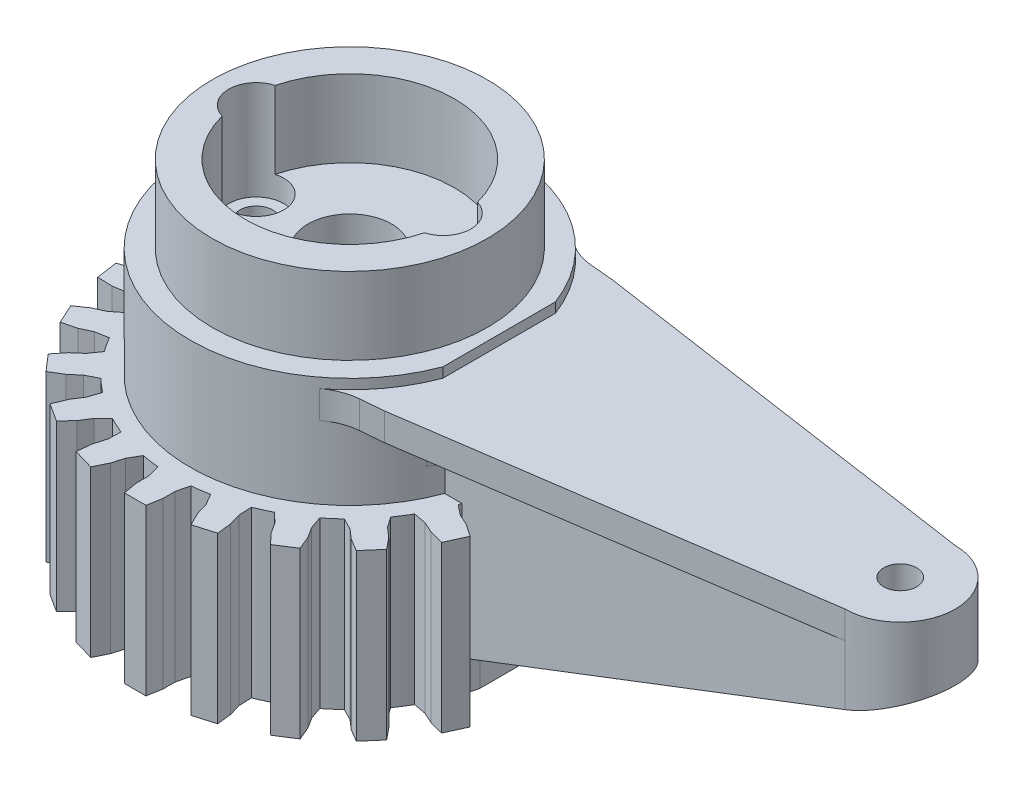
from build123d import *

# Parameters (mm, degrees)
SKETCH1_R            = 14.5
BOSS_EXTRUDE1_DEPTH  = 2
SKETCH2_R            = 3.8
SKETCH2_R_2          = 1.5
CUT_EXTRUDE1_DEPTH   = 2.5
BOSS_EXTRUDE2_START  = 7
SKETCH3_R            = 14.5
SKETCH3_R_2          = 12.5
BOSS_EXTRUDE2_DEPTH  = 7
BOSS_EXTRUDE3_START  = 1
SKETCH4_R            = 14.5
SKETCH4_R_2          = 3.8
SKETCH4_R_3          = 1.5
BOSS_EXTRUDE3_DEPTH  = 1
SKETCH5_R            = 2.6
SKETCH5_R_2          = 2.5
CUT_EXTRUDE2_DEPTH   = 2
BOSS_EXTRUDE4_START  = -3.5
SKETCH6_R            = 1.5
BOSS_EXTRUDE4_DEPTH  = 3.5
BOSS_EXTRUDE5_START  = 30
SKETCH9_R            = 12.5
BOSS_EXTRUDE5_DEPTH  = 30
SKETCH15_R           = 12.5
SKETCH15_R_2         = 9.5
BOSS_EXTRUDE9_DEPTH  = 7
SKETCH17_R           = 2.5
CUT_EXTRUDE5_DEPTH   = 7
SKETCH18_W           = 71.644805376
SKETCH18_H           = 13.532805393
CUT_EXTRUDE6_DEPTH   = 0.9
SKETCH19_W           = 61.579455678
SKETCH19_H           = 54.934190677
CUT_EXTRUDE7_DEPTH   = 15
BOSS_EXTRUDE14_START = -2.5
BOSS_EXTRUDE14_DEPTH = 2.5
FILLET2_R            = 5
SKETCH21_W           = 41.145247831
SKETCH21_H           = 10
BOSS_EXTRUDE15_DEPTH = 4
CUT_EXTRUDE8_DEPTH   = 17
FILLET5_R            = 2
CUT_EXTRUDE9_START   = -8
SKETCH23_R           = 1.5
CUT_EXTRUDE9_DEPTH   = 8
SKETCH24_R           = 1.5
CUT_EXTRUDE10_DEPTH  = 8
SKETCH27_W           = 31.221224177
SKETCH27_H           = 10
BOSS_EXTRUDE16_DEPTH = 19
CUT_EXTRUDE11_DEPTH  = 10
CUT_EXTRUDE12_DEPTH  = 3
SKETCH33_R           = 5
SKETCH33_R_2         = 1.5
BOSS_EXTRUDE19_DEPTH = 6
BOSS_EXTRUDE20_DEPTH = 5
BOSS_EXTRUDE21_DEPTH = 10
CUT_EXTRUDE13_START  = -10
SKETCH36_R           = 1.5
CUT_EXTRUDE13_DEPTH  = 10


with BuildPart() as part:
    # Sketch1 → Boss-Extrude1 (new body)
    with BuildSketch(Plane(origin=(0, 0, 0), x_dir=(1, 0, 0), z_dir=(0, 1, 0))):
        Circle(SKETCH1_R)
    extrude(amount=BOSS_EXTRUDE1_DEPTH)

    # Sketch2 → Cut-Extrude1 (cut)
    with BuildSketch(Plane(origin=(0, 2, 0), x_dir=(1, 0, 0), z_dir=(0, 1, 0))):
        Circle(SKETCH2_R)
        with Locations((-8.5, 0)):
            Circle(SKETCH2_R_2)
        with Locations((8.5, 0)):
            Circle(SKETCH2_R_2)
    extrude(amount=-CUT_EXTRUDE1_DEPTH, mode=Mode.SUBTRACT)

    # Sketch3 → Boss-Extrude2 (add)
    with BuildSketch(Plane.XZ.offset(BOSS_EXTRUDE2_START)):
        Circle(SKETCH3_R)
        Circle(SKETCH3_R_2, mode=Mode.SUBTRACT)
    extrude(amount=-BOSS_EXTRUDE2_DEPTH)

    # Sketch4 → Boss-Extrude3 (add)
    with BuildSketch(Plane(origin=(0, 2, 0), x_dir=(1, 0, 0), z_dir=(0, 1, 0)).offset(BOSS_EXTRUDE3_START)):
        Circle(SKETCH4_R)
        Circle(SKETCH4_R_2, mode=Mode.SUBTRACT)
        with Locations((8.5, 0)):
            Circle(SKETCH4_R_3, mode=Mode.SUBTRACT)
        with Locations((-8.5, 0)):
            Circle(SKETCH4_R_3, mode=Mode.SUBTRACT)
    extrude(amount=-BOSS_EXTRUDE3_DEPTH)

    # Sketch5 → Cut-Extrude2 (cut)
    with BuildSketch(Plane(origin=(0, 3, 0), x_dir=(1, 0, 0), z_dir=(0, 1, 0))):
        with Locations((8.5, 0)):
            Circle(SKETCH5_R)
        with Locations((-8.5, 0)):
            Circle(SKETCH5_R_2)
    extrude(amount=-CUT_EXTRUDE2_DEPTH, mode=Mode.SUBTRACT)

    # Sketch6 → Boss-Extrude4 (add)
    with BuildSketch(Plane(origin=(0, 3, 0), x_dir=(1, 0, 0), z_dir=(0, 1, 0)).offset(BOSS_EXTRUDE4_START)):
        with BuildLine():
            Line((70, 5), (60, 5))
            Line((60, 5), (13.610657589, 5))
            ThreePointArc((13.610657589, 5), (14.275933158, 2.539238563), (14.5, 0))
            ThreePointArc((14.5, 0), (14.275933158, -2.539238563), (13.610657589, -5))
            Line((13.610657589, -5), (60, -5))
            Line((60, -5), (70, -5))
            Line((70, -5), (73, -5))
            ThreePointArc((73, -5), (78, 0), (73, 5))
            Line((73, 5), (70, 5))
        make_face()
        with Locations((73, 0)):
            Circle(SKETCH6_R, mode=Mode.SUBTRACT)
    extrude(amount=BOSS_EXTRUDE4_DEPTH)

    # Sketch9 → Boss-Extrude5 (add)
    with BuildSketch(Plane(origin=(0, -7, 0), x_dir=(-1, 0, 0), z_dir=(0, -1, 0)).offset(BOSS_EXTRUDE5_START)):
        with BuildLine():
            Line((0.977254255, 19.494569665), (-0.977254255, 19.494569665))
            Line((-0.977254255, 19.494569665), (-1.208206331, 18.184775353))
            Line((-1.208206331, 18.184775353), (-1.208206331, 17.065775353))
            Line((-1.208206331, 17.065775353), (-1.493190324, 15.922766988))
            ThreePointArc((-1.493190324, 15.922766988), (-2.275988159, 15.82984535), (-3.053256231, 15.698463373))
            Line((-3.053256231, 15.698463373), (-3.648719039, 16.7148826))
            Line((-3.648719039, 16.7148826), (-3.96397777, 17.788555237))
            Line((-3.96397777, 17.788555237), (-4.554586365, 18.980226957))
            Line((-4.554586365, 18.980226957), (-6.429923547, 18.429578277))
            Line((-6.429923547, 18.429578277), (-6.282508741, 17.107773119))
            Line((-6.282508741, 17.107773119), (-5.96725001, 16.034100482))
            Line((-5.96725001, 16.034100482), (-5.91866748, 14.857102717))
            ThreePointArc((-5.91866748, 14.857102717), (-6.643577451, 14.547405423), (-7.352346125, 14.202363618))
            Line((-7.352346125, 14.202363618), (-8.210046893, 15.009849465))
            Line((-8.210046893, 15.009849465), (-8.815023968, 15.951212168))
            Line((-8.815023968, 15.951212168), (-9.717441485, 16.928219141))
            Line((-9.717441485, 16.928219141), (-11.361678674, 15.871532062))
            Line((-11.361678674, 15.871532062), (-10.847839657, 14.644800851))
            Line((-10.847839657, 14.644800851), (-10.242862582, 13.703438148))
            Line((-10.242862582, 13.703438148), (-9.864649396, 12.587804343))
            ThreePointArc((-9.864649396, 12.587804343), (-10.472943609, 12.086421226), (-11.055792662, 11.555672828))
            Line((-11.055792662, 11.555672828), (-12.106245574, 12.088807594))
            Line((-12.106245574, 12.088807594), (-12.951929348, 12.821596755))
            Line((-12.951929348, 12.821596755), (-14.093047288, 13.504787686))
            Line((-14.093047288, 13.504787686), (-15.372978165, 12.027668711))
            Line((-15.372978165, 12.027668711), (-14.534343118, 10.995393914))
            Line((-14.534343118, 10.995393914), (-13.688659344, 10.262604753))
            Line((-13.688659344, 10.262604753), (-13.011456085, 9.298716924))
            ThreePointArc((-13.011456085, 9.298716924), (-13.453854161, 8.646267062), (-13.863564629, 7.972810149))
            Line((-13.863564629, 7.972810149), (-15.021668238, 8.188402426))
            Line((-15.021668238, 8.188402426), (-16.039546441, 8.653251826))
            Line((-16.039546441, 8.653251826), (-17.326918214, 8.987278649))
            Line((-17.326918214, 8.987278649), (-18.138850392, 7.209395173))
            Line((-18.138850392, 7.209395173), (-17.043360539, 6.455205554))
            Line((-17.043360539, 6.455205554), (-16.025482336, 5.990356154))
            Line((-16.025482336, 5.990356154), (-15.104151985, 5.256302761))
            ThreePointArc((-15.104151985, 5.256302761), (-15.344813462, 4.505643762), (-15.548193039, 3.744037809))
            Line((-15.548193039, 3.744037809), (-16.720124678, 3.624621592))
            Line((-16.720124678, 3.624621592), (-17.827734872, 3.783871896))
            Line((-17.827734872, 3.783871896), (-19.157065273, 3.741673745))
            Line((-19.157065273, 3.741673745), (-19.435220836, 1.807059313))
            Line((-19.435220836, 1.807059313), (-18.171626249, 1.39205483))
            Line((-18.171626249, 1.39205483), (-17.064016056, 1.232804526))
            Line((-17.064016056, 1.232804526), (-15.973199318, 0.788054209))
            ThreePointArc((-15.973199318, 0.788054209), (-15.992627235, 0), (-15.973199318, -0.788054209))
            Line((-15.973199318, -0.788054209), (-17.064016056, -1.232804526))
            Line((-17.064016056, -1.232804526), (-18.171626249, -1.39205483))
            Line((-18.171626249, -1.39205483), (-19.435220836, -1.807059313))
            Line((-19.435220836, -1.807059313), (-19.157065273, -3.741673745))
            Line((-19.157065273, -3.741673745), (-17.827734872, -3.783871896))
            Line((-17.827734872, -3.783871896), (-16.720124678, -3.624621592))
            Line((-16.720124678, -3.624621592), (-15.548193039, -3.744037809))
            ThreePointArc((-15.548193039, -3.744037809), (-15.344813462, -4.505643762), (-15.104151985, -5.256302761))
            Line((-15.104151985, -5.256302761), (-16.025482336, -5.990356154))
            Line((-16.025482336, -5.990356154), (-17.043360539, -6.455205554))
            Line((-17.043360539, -6.455205554), (-18.138850392, -7.209395173))
            Line((-18.138850392, -7.209395173), (-17.326918214, -8.987278649))
            Line((-17.326918214, -8.987278649), (-16.039546441, -8.653251826))
            Line((-16.039546441, -8.653251826), (-15.021668238, -8.188402426))
            Line((-15.021668238, -8.188402426), (-13.863564629, -7.972810149))
            ThreePointArc((-13.863564629, -7.972810149), (-13.453854161, -8.646267062), (-13.011456085, -9.298716924))
            Line((-13.011456085, -9.298716924), (-13.688659344, -10.262604753))
            Line((-13.688659344, -10.262604753), (-14.534343118, -10.995393914))
            Line((-14.534343118, -10.995393914), (-15.372978165, -12.027668711))
            Line((-15.372978165, -12.027668711), (-14.093047288, -13.504787686))
            Line((-14.093047288, -13.504787686), (-12.951929348, -12.821596755))
            Line((-12.951929348, -12.821596755), (-12.106245574, -12.088807594))
            Line((-12.106245574, -12.088807594), (-11.055792662, -11.555672828))
            ThreePointArc((-11.055792662, -11.555672828), (-10.472943609, -12.086421226), (-9.864649396, -12.587804343))
            Line((-9.864649396, -12.587804343), (-10.242862582, -13.703438148))
            Line((-10.242862582, -13.703438148), (-10.847839657, -14.644800851))
            Line((-10.847839657, -14.644800851), (-11.361678674, -15.871532062))
            Line((-11.361678674, -15.871532062), (-9.717441485, -16.928219141))
            Line((-9.717441485, -16.928219141), (-8.815023968, -15.951212168))
            Line((-8.815023968, -15.951212168), (-8.210046893, -15.009849465))
            Line((-8.210046893, -15.009849465), (-7.352346125, -14.202363618))
            ThreePointArc((-7.352346125, -14.202363618), (-6.643577451, -14.547405423), (-5.91866748, -14.857102717))
            Line((-5.91866748, -14.857102717), (-5.96725001, -16.034100482))
            Line((-5.96725001, -16.034100482), (-6.282508741, -17.107773119))
            Line((-6.282508741, -17.107773119), (-6.429923547, -18.429578277))
            Line((-6.429923547, -18.429578277), (-4.554586365, -18.980226957))
            Line((-4.554586365, -18.980226957), (-3.96397777, -17.788555237))
            Line((-3.96397777, -17.788555237), (-3.648719039, -16.7148826))
            Line((-3.648719039, -16.7148826), (-3.053256231, -15.698463373))
            ThreePointArc((-3.053256231, -15.698463373), (-2.275988159, -15.82984535), (-1.493190324, -15.922766988))
            Line((-1.493190324, -15.922766988), (-1.208206331, -17.065775353))
            Line((-1.208206331, -17.065775353), (-1.208206331, -18.184775353))
            Line((-1.208206331, -18.184775353), (-0.977254255, -19.494569665))
            Line((-0.977254255, -19.494569665), (0.977254255, -19.494569665))
            Line((0.977254255, -19.494569665), (1.208206331, -18.184775353))
            Line((1.208206331, -18.184775353), (1.208206331, -17.065775353))
            Line((1.208206331, -17.065775353), (1.493190324, -15.922766988))
            ThreePointArc((1.493190324, -15.922766988), (2.275988159, -15.82984535), (3.053256231, -15.698463373))
            Line((3.053256231, -15.698463373), (3.648719039, -16.7148826))
            Line((3.648719039, -16.7148826), (3.96397777, -17.788555237))
            Line((3.96397777, -17.788555237), (4.554586365, -18.980226957))
            Line((4.554586365, -18.980226957), (6.429923547, -18.429578277))
            Line((6.429923547, -18.429578277), (6.282508741, -17.107773119))
            Line((6.282508741, -17.107773119), (5.96725001, -16.034100482))
            Line((5.96725001, -16.034100482), (5.91866748, -14.857102717))
            ThreePointArc((5.91866748, -14.857102717), (6.643577451, -14.547405423), (7.352346125, -14.202363618))
            Line((7.352346125, -14.202363618), (8.210046893, -15.009849465))
            Line((8.210046893, -15.009849465), (8.815023968, -15.951212168))
            Line((8.815023968, -15.951212168), (9.717441485, -16.928219141))
            Line((9.717441485, -16.928219141), (11.361678674, -15.871532062))
            Line((11.361678674, -15.871532062), (10.847839657, -14.644800851))
            Line((10.847839657, -14.644800851), (10.242862582, -13.703438148))
            Line((10.242862582, -13.703438148), (9.864649396, -12.587804343))
            ThreePointArc((9.864649396, -12.587804343), (10.472943609, -12.086421226), (11.055792662, -11.555672828))
            Line((11.055792662, -11.555672828), (12.106245574, -12.088807594))
            Line((12.106245574, -12.088807594), (12.951929348, -12.821596755))
            Line((12.951929348, -12.821596755), (14.093047288, -13.504787686))
            Line((14.093047288, -13.504787686), (15.372978165, -12.027668711))
            Line((15.372978165, -12.027668711), (14.534343118, -10.995393914))
            Line((14.534343118, -10.995393914), (13.688659344, -10.262604753))
            Line((13.688659344, -10.262604753), (13.011456085, -9.298716924))
            ThreePointArc((13.011456085, -9.298716924), (13.453854161, -8.646267062), (13.863564629, -7.972810149))
            Line((13.863564629, -7.972810149), (15.021668238, -8.188402426))
            Line((15.021668238, -8.188402426), (16.039546441, -8.653251826))
            Line((16.039546441, -8.653251826), (17.326918214, -8.987278649))
            Line((17.326918214, -8.987278649), (18.138850392, -7.209395173))
            Line((18.138850392, -7.209395173), (17.043360539, -6.455205554))
            Line((17.043360539, -6.455205554), (16.025482336, -5.990356154))
            Line((16.025482336, -5.990356154), (15.104151985, -5.256302761))
            ThreePointArc((15.104151985, -5.256302761), (15.344813462, -4.505643762), (15.548193039, -3.744037809))
            Line((15.548193039, -3.744037809), (16.720124678, -3.624621592))
            Line((16.720124678, -3.624621592), (17.827734872, -3.783871896))
            Line((17.827734872, -3.783871896), (19.157065273, -3.741673745))
            Line((19.157065273, -3.741673745), (19.435220836, -1.807059313))
            Line((19.435220836, -1.807059313), (18.171626249, -1.39205483))
            Line((18.171626249, -1.39205483), (17.064016056, -1.232804526))
            Line((17.064016056, -1.232804526), (15.973199318, -0.788054209))
            ThreePointArc((15.973199318, -0.788054209), (15.992627235, 0), (15.973199318, 0.788054209))
            Line((15.973199318, 0.788054209), (17.064016056, 1.232804526))
            Line((17.064016056, 1.232804526), (18.171626249, 1.39205483))
            Line((18.171626249, 1.39205483), (19.435220836, 1.807059313))
            Line((19.435220836, 1.807059313), (19.157065273, 3.741673745))
            Line((19.157065273, 3.741673745), (17.827734872, 3.783871896))
            Line((17.827734872, 3.783871896), (16.720124678, 3.624621592))
            Line((16.720124678, 3.624621592), (15.548193039, 3.744037809))
            ThreePointArc((15.548193039, 3.744037809), (15.344813462, 4.505643762), (15.104151985, 5.256302761))
            Line((15.104151985, 5.256302761), (16.025482336, 5.990356154))
            Line((16.025482336, 5.990356154), (17.043360539, 6.455205554))
            Line((17.043360539, 6.455205554), (18.138850392, 7.209395173))
            Line((18.138850392, 7.209395173), (17.326918214, 8.987278649))
            Line((17.326918214, 8.987278649), (16.039546441, 8.653251826))
            Line((16.039546441, 8.653251826), (15.021668238, 8.188402426))
            Line((15.021668238, 8.188402426), (13.863564629, 7.972810149))
            ThreePointArc((13.863564629, 7.972810149), (13.453854161, 8.646267062), (13.011456085, 9.298716924))
            Line((13.011456085, 9.298716924), (13.688659344, 10.262604753))
            Line((13.688659344, 10.262604753), (14.534343118, 10.995393914))
            Line((14.534343118, 10.995393914), (15.372978165, 12.027668711))
            Line((15.372978165, 12.027668711), (14.093047288, 13.504787686))
            Line((14.093047288, 13.504787686), (12.951929348, 12.821596755))
            Line((12.951929348, 12.821596755), (12.106245574, 12.088807594))
            Line((12.106245574, 12.088807594), (11.055792662, 11.555672828))
            ThreePointArc((11.055792662, 11.555672828), (10.472943609, 12.086421226), (9.864649396, 12.587804343))
            Line((9.864649396, 12.587804343), (10.242862582, 13.703438148))
            Line((10.242862582, 13.703438148), (10.847839657, 14.644800851))
            Line((10.847839657, 14.644800851), (11.361678674, 15.871532062))
            Line((11.361678674, 15.871532062), (9.717441485, 16.928219141))
            Line((9.717441485, 16.928219141), (8.815023968, 15.951212168))
            Line((8.815023968, 15.951212168), (8.210046893, 15.009849465))
            Line((8.210046893, 15.009849465), (7.352346125, 14.202363618))
            ThreePointArc((7.352346125, 14.202363618), (6.643577451, 14.547405423), (5.91866748, 14.857102717))
            Line((5.91866748, 14.857102717), (5.96725001, 16.034100482))
            Line((5.96725001, 16.034100482), (6.282508741, 17.107773119))
            Line((6.282508741, 17.107773119), (6.429923547, 18.429578277))
            Line((6.429923547, 18.429578277), (4.554586365, 18.980226957))
            Line((4.554586365, 18.980226957), (3.96397777, 17.788555237))
            Line((3.96397777, 17.788555237), (3.648719039, 16.7148826))
            Line((3.648719039, 16.7148826), (3.053256231, 15.698463373))
            ThreePointArc((3.053256231, 15.698463373), (2.275988159, 15.82984535), (1.493190324, 15.922766988))
            Line((1.493190324, 15.922766988), (1.208206331, 17.065775353))
            Line((1.208206331, 17.065775353), (1.208206331, 18.184775353))
            Line((1.208206331, 18.184775353), (0.977254255, 19.494569665))
        make_face()
        Circle(SKETCH9_R, mode=Mode.SUBTRACT)
    extrude(amount=-BOSS_EXTRUDE5_DEPTH)

    # Sketch15 → Boss-Extrude9 (add)
    with BuildSketch(Plane(origin=(0, 3, 0), x_dir=(1, 0, 0), z_dir=(0, 1, 0))):
        Circle(SKETCH15_R)
        Circle(SKETCH15_R_2, mode=Mode.SUBTRACT)
    extrude(amount=BOSS_EXTRUDE9_DEPTH)

    # Sketch17 → Cut-Extrude5 (cut)
    with BuildSketch(Plane(origin=(0, 10, 0), x_dir=(1, 0, 0), z_dir=(0, 1, 0))):
        with Locations((-8.5, 0)):
            Circle(SKETCH17_R)
        with Locations((8.5, 0)):
            Circle(SKETCH17_R)
    extrude(amount=-CUT_EXTRUDE5_DEPTH, mode=Mode.SUBTRACT)

    # Sketch18 → Cut-Extrude6 (cut)
    with BuildSketch(Plane(origin=(0, 3, 0), x_dir=(1, 0, 0), z_dir=(0, 1, 0))):
        with Locations((49.390967321, 0.047988672)):
            Rectangle(SKETCH18_W, SKETCH18_H)
    extrude(amount=-CUT_EXTRUDE6_DEPTH, mode=Mode.SUBTRACT)

    # Sketch19 → Cut-Extrude7 (cut)
    with BuildSketch(Plane.XZ.offset(37)):
        with Locations((0.59699566, 2.52896314)):
            Rectangle(SKETCH19_W, SKETCH19_H)
    extrude(amount=-CUT_EXTRUDE7_DEPTH, mode=Mode.SUBTRACT)

    # Sketch20 → Boss-Extrude14 (add)
    with BuildSketch(Plane(origin=(0, 2.1, 0), x_dir=(1, 0, 0), z_dir=(0, 1, 0)).offset(BOSS_EXTRUDE14_START)):
        with BuildLine():
            Line((73, 5), (9.826262276, 10.662765574))
            ThreePointArc((9.826262276, 10.662765574), (12.022025927, 8.106842333), (13.568564633, 5.113125638))
            Line((13.568564633, 5.113125638), (13.568564633, 4.679970228))
            Line((13.568564633, 4.679970228), (73, 5))
        make_face()
        with BuildLine():
            Line((73, -5), (13.568564633, -4.679970228))
            Line((13.568564633, -4.679970228), (13.568564633, -5.113125638))
            ThreePointArc((13.568564633, -5.113125638), (12.022025927, -8.106842333), (9.826262276, -10.662765574))
            Line((9.826262276, -10.662765574), (73, -5))
        make_face()
    extrude(amount=BOSS_EXTRUDE14_DEPTH)

    # Fillet2
    fillet2_edges = [part.edges().sort_by_distance(p)[0] for p in [
        (9.826262276, 0.85, -10.662765574),
        (9.826262276, 0.85, 10.662765574),
    ]]
    fillet(fillet2_edges, radius=FILLET2_R)

    # Sketch21 → Boss-Extrude15 (add)
    with BuildSketch(Plane.XZ.offset(0.5)):
        with Locations((34.183281505, 0)):
            Rectangle(SKETCH21_W, SKETCH21_H)
    extrude(amount=BOSS_EXTRUDE15_DEPTH)

    # Sketch22 → Cut-Extrude8 (cut)
    with BuildSketch(Plane.XY.offset(5)):
        Polygon((13.610657589, -4.5), (54.75590542, -0.5), (54.75590542, -4.5), align=None)
    extrude(amount=-CUT_EXTRUDE8_DEPTH, mode=Mode.SUBTRACT)

    # Fillet5
    fillet5_edges = [part.edges().sort_by_distance(p)[0] for p in [
        (13.610657589, -2.45, 5),
        (13.610657589, -2.45, -5),
    ]]
    fillet(fillet5_edges, radius=FILLET5_R)

    # Sketch23 → Cut-Extrude9 (cut)
    with BuildSketch(Plane(origin=(0, 2.1, 0), x_dir=(1, 0, 0), z_dir=(0, 1, 0)).offset(CUT_EXTRUDE9_START)):
        with BuildLine():
            Line((87.315150579, 10.842776966), (10.017026632, 10.842776966))
            Line((10.017026632, 10.842776966), (50, 5))
            ThreePointArc((50, 5), (55, 0), (50, -5))
            Line((50, -5), (10.017026632, -10.842776966))
            Line((10.017026632, -10.842776966), (87.315150579, -12.753493544))
            Line((87.315150579, -12.753493544), (87.315150579, 10.842776966))
        make_face()
        with Locations((73, 0)):
            Circle(SKETCH23_R, mode=Mode.SUBTRACT)
    extrude(amount=CUT_EXTRUDE9_DEPTH, mode=Mode.SUBTRACT)

    # Sketch24 → Cut-Extrude10 (cut)
    with BuildSketch(Plane(origin=(0, 2.1, 0), x_dir=(1, 0, 0), z_dir=(0, 1, 0))):
        with Locations((50, 0)):
            Circle(SKETCH24_R)
    extrude(amount=-CUT_EXTRUDE10_DEPTH, mode=Mode.SUBTRACT)

    # Sketch27 → Boss-Extrude16 (add)
    with BuildSketch(Plane.XZ.offset(0.4)):
        with Locations((29.247093854, 0)):
            Rectangle(SKETCH27_W, SKETCH27_H)
    extrude(amount=BOSS_EXTRUDE16_DEPTH)

    # Sketch28 → Cut-Extrude11 (cut)
    with BuildSketch(Plane(origin=(0, 0, -5), x_dir=(-1, 0, 0), z_dir=(0, 0, -1))):
        Polygon((-15.190922483, -19.147676102), (-44.857705942, -1.462269035), (-44.857705942, -19.4), (-15.190922483, -19.4), align=None)
    extrude(amount=-CUT_EXTRUDE11_DEPTH, mode=Mode.SUBTRACT)

    # Sketch29 → Cut-Extrude12 (cut)
    with BuildSketch(Plane.XZ.offset(22)):
        Polygon((15.548193039, 3.744037809), (15.548193039, -3.744037809), (22.351349218, -4.315128545), (21.843687036, 6.007335817), align=None)
    extrude(amount=-CUT_EXTRUDE12_DEPTH, mode=Mode.SUBTRACT)

    # Sketch33 → Boss-Extrude19 (add)
    with BuildSketch(Plane(origin=(0, 2.1, 0), x_dir=(1, 0, 0), z_dir=(0, 1, 0))):
        with Locations((50, 0)):
            Circle(SKETCH33_R)
        with Locations((50, 0)):
            Circle(SKETCH33_R_2, mode=Mode.SUBTRACT)
    extrude(amount=-BOSS_EXTRUDE19_DEPTH)

    # Sketch34 → Boss-Extrude20 (add)
    with BuildSketch(Plane.XZ.offset(3.9)):
        with BuildLine():
            ThreePointArc((50, -5), (45, 0), (50, 5))
            Line((50, 5), (36.344090991, 5))
            Line((36.344090991, 5), (36.344090991, -5))
            Line((36.344090991, -5), (50, -5))
        make_face()
    extrude(amount=-BOSS_EXTRUDE20_DEPTH)

    # Sketch35 → Boss-Extrude21 (add)
    with BuildSketch(Plane(origin=(0, 0, -5), x_dir=(-1, 0, 0), z_dir=(0, 0, -1))):
        Polygon((-15.190922483, -19.147676102), (-14.988107576, -3.9), (-55, -3.9), align=None)
    extrude(amount=-BOSS_EXTRUDE21_DEPTH)

    # Sketch36 → Cut-Extrude13 (cut)
    with BuildSketch(Plane(origin=(0, 2.1, 0), x_dir=(1, 0, 0), z_dir=(0, 1, 0)).offset(CUT_EXTRUDE13_START)):
        with BuildLine():
            Line((55, -5), (55, 0))
            ThreePointArc((55, 0), (53.535533906, -3.535533906), (50, -5))
            Line((50, -5), (55, -5))
        make_face()
        with BuildLine():
            Line((55, 5), (50, 5))
            ThreePointArc((50, 5), (53.535533906, 3.535533906), (55, 0))
            Line((55, 0), (55, 5))
        make_face()
        with Locations((50, 0)):
            Circle(SKETCH36_R)
    extrude(amount=CUT_EXTRUDE13_DEPTH, mode=Mode.SUBTRACT)


solid = part.part
